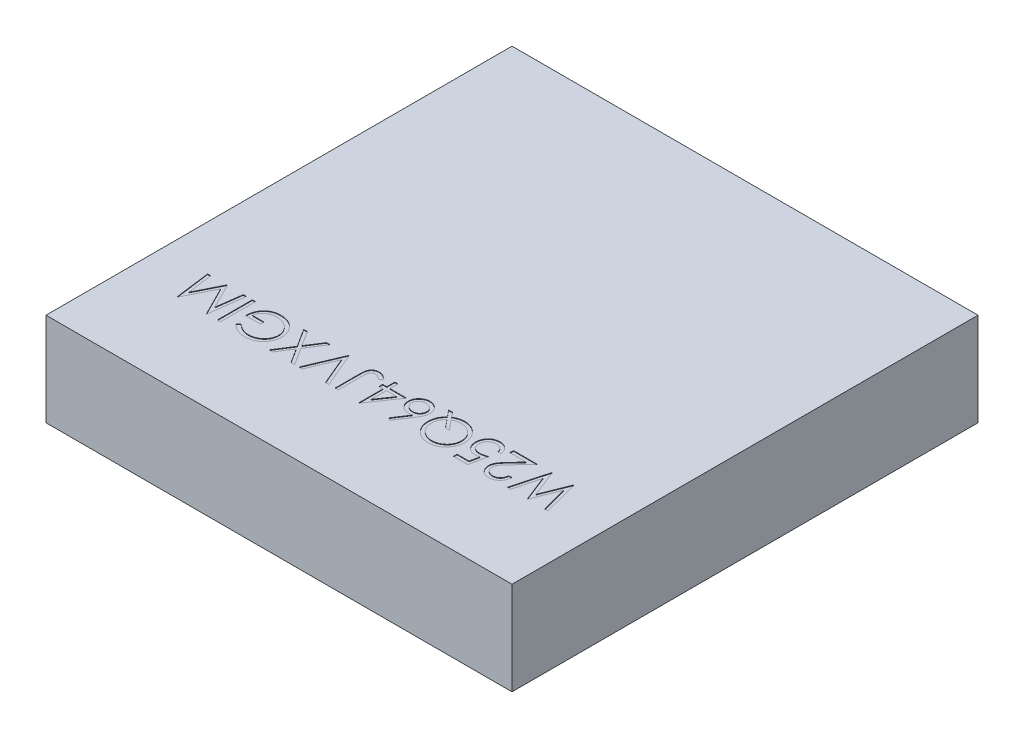
from build123d import *

# Parameters (mm, degrees)
BASES_W          = 4
BASES_H          = 4
BASE_DEPTH       = 0.8
PARTNUMBERS_W    = 0.026923077
PARTNUMBERS_H    = 0.3
PARTNUMBER_DEPTH = 0.005


with BuildPart() as part:
    # BaseS → Base (new body)
    with BuildSketch(Plane(origin=(0, 0, 0), x_dir=(1, 0, 0), z_dir=(0, 1, 0))):
        Rectangle(BASES_W, BASES_H)
    extrude(amount=BASE_DEPTH)

    # PartNumberS → PartNumber (cut)
    with BuildSketch(Plane(origin=(0, 0.8, 0), x_dir=(1, 0, 0), z_dir=(0, 1, 0))):
        Polygon((1.609615385, -1.3), (1.581790865, -1.3), (1.523076923, -1.079987981), (1.435757212, -1.3), (1.431850962, -1.3), (1.346153846, -1.081490385), (1.287139423, -1.3), (1.259615385, -1.3), (1.340504808, -1), (1.344350962, -1), (1.434615385, -1.229447115), (1.525961538, -1), (1.529807692, -1), align=None)
        with BuildLine():
            Line((1.178846154, -1.207692308), (1.205769231, -1.207692308))
            add(Edge.make_bspline(
                [(1.205769231, -1.207692308), (1.20559379, -1.211264116), (1.20524923, -1.218279052), (1.203634954, -1.228506566), (1.201327266, -1.238283593), (1.198056733, -1.247526313), (1.19401791, -1.256345139), (1.189073223, -1.264622965), (1.183328083, -1.272441949), (1.176793031, -1.279654052), (1.169701897, -1.286246815), (1.162097168, -1.29200025), (1.154057007, -1.296805723), (1.14565115, -1.300844834), (1.136782381, -1.303872996), (1.127535475, -1.306120829), (1.117868638, -1.307473016), (1.111282358, -1.307618379), (1.107932692, -1.307692308)],
                knots=[0, 0, 0, 0, 1.100776268, 2.161895295, 3.184016182, 4.190939212, 5.176500551, 6.166955529, 7.155448256, 8.160289653, 9.16017456, 10.133824356, 11.091467644, 12.04088621, 13.000931625, 13.972173743, 14.968683325, 16, 16, 16, 16], degree=3))
            add(Edge.make_bspline(
                [(1.107932692, -1.307692308), (1.104642912, -1.307615922), (1.09817861, -1.307465827), (1.088747998, -1.306157469), (1.079748932, -1.304152528), (1.071283399, -1.301181521), (1.063264519, -1.297453556), (1.055791578, -1.292817344), (1.048683874, -1.287492254), (1.042290239, -1.28121105), (1.036416914, -1.274508988), (1.031354464, -1.267351243), (1.026994641, -1.259949914), (1.023426262, -1.252247187), (1.020721273, -1.244217976), (1.018717135, -1.235939262), (1.017571461, -1.227315502), (1.017396595, -1.221477629), (1.017307692, -1.218509615)],
                knots=[0, 0, 0, 0, 1.111674182, 2.184400057, 3.212814286, 4.223731311, 5.211378316, 6.196328225, 7.191884489, 8.207283132, 9.220262353, 10.201199469, 11.166417575, 12.120932471, 13.06540007, 14.026332106, 14.996573967, 16, 16, 16, 16], degree=3))
            add(Edge.make_bspline(
                [(1.017307692, -1.218509615), (1.017452831, -1.214331231), (1.017740563, -1.206047788), (1.020201761, -1.193875059), (1.024045875, -1.182081438), (1.02867381, -1.172589346), (1.033343795, -1.164941485), (1.03754792, -1.158641505), (1.042497533, -1.151859905), (1.048150348, -1.144569237), (1.054603713, -1.136864979), (1.061689971, -1.128589943), (1.069592128, -1.119897139), (1.075133439, -1.113955969), (1.078004808, -1.110877404)],
                knots=[0, 0, 0, 0, 1.184416499, 2.348048165, 3.509039915, 4.696071444, 5.333504901, 6.05069495, 6.844171097, 7.714965912, 8.667477798, 9.695072654, 10.805644396, 12, 12, 12, 12], degree=3))
            Line((1.078004808, -1.110877404), (1.153064904, -1.030769231))
            Line((1.153064904, -1.030769231), (1.013461538, -1.030769231))
            Line((1.013461538, -1.030769231), (1.013461538, -1))
            Line((1.013461538, -1), (1.217307692, -1))
            Line((1.217307692, -1), (1.100961538, -1.124158654))
            add(Edge.make_bspline(
                [(1.100961538, -1.124158654), (1.098128662, -1.12711549), (1.092687286, -1.132794968), (1.084994275, -1.141089344), (1.0780736, -1.148775115), (1.07192067, -1.15588634), (1.066530422, -1.162382705), (1.061920103, -1.16831512), (1.058069336, -1.173632674), (1.053988325, -1.179879515), (1.050096811, -1.187515589), (1.046676568, -1.196800331), (1.044605999, -1.206379382), (1.044356347, -1.212850661), (1.044230769, -1.216105769)],
                knots=[0, 0, 0, 0, 1.329530082, 2.553755191, 3.672934919, 4.687409497, 5.60679272, 6.413407421, 7.126401618, 7.737995624, 8.834647426, 9.90044882, 10.943907757, 12, 12, 12, 12], degree=3))
            add(Edge.make_bspline(
                [(1.044230769, -1.216105769), (1.044284702, -1.218152972), (1.044390992, -1.222187617), (1.045346826, -1.228099151), (1.046751136, -1.233823625), (1.048915611, -1.23929026), (1.051516148, -1.244606575), (1.054838526, -1.249610936), (1.058635132, -1.254473931), (1.063039008, -1.259028812), (1.067873646, -1.26320179), (1.072981891, -1.266898061), (1.078386142, -1.269987148), (1.084063878, -1.272519442), (1.089999201, -1.274505905), (1.096203609, -1.275882354), (1.102659953, -1.276746568), (1.107068538, -1.276863497), (1.109314904, -1.276923077)],
                knots=[0, 0, 0, 0, 0.991504627, 1.954065223, 2.895985987, 3.842598665, 4.797835564, 5.759220273, 6.74786863, 7.784730864, 8.824135544, 9.839918996, 10.835834653, 11.835434876, 12.84861661, 13.863796685, 14.911511676, 16, 16, 16, 16], degree=3))
            add(Edge.make_bspline(
                [(1.109314904, -1.276923077), (1.111661575, -1.276864225), (1.116270048, -1.276748651), (1.123021768, -1.27587269), (1.12950777, -1.274546092), (1.135628106, -1.272434159), (1.141510864, -1.269962418), (1.147005973, -1.266761947), (1.152267796, -1.263104915), (1.157190543, -1.258841048), (1.161674102, -1.254027783), (1.165752836, -1.24878863), (1.169208787, -1.243030709), (1.1722766, -1.236892182), (1.174622872, -1.230204399), (1.176628766, -1.223130918), (1.178085818, -1.215570817), (1.178588499, -1.210362095), (1.178846154, -1.207692308)],
                knots=[0, 0, 0, 0, 1.031072318, 2.024855787, 2.988461151, 3.935103592, 4.865765533, 5.788564469, 6.724086513, 7.67908574, 8.64457978, 9.611397706, 10.591395687, 11.591555111, 12.622101007, 13.700900657, 14.821571223, 16, 16, 16, 16], degree=3))
        make_face()
        with BuildLine():
            Line((0.798076923, -1.3), (0.798076923, -1.269230769))
            Line((0.798076923, -1.269230769), (0.900120192, -1.269230769))
            Line((0.900120192, -1.269230769), (0.916286058, -1.190324519))
            add(Edge.make_bspline(
                [(0.916286058, -1.190324519), (0.91310984, -1.1912014), (0.90695642, -1.192900217), (0.897874146, -1.194786426), (0.889251958, -1.195923464), (0.883656926, -1.196078719), (0.880949519, -1.196153846)],
                knots=[0, 0, 0, 0, 1.100273476, 2.13160584, 3.095893838, 4, 4, 4, 4], degree=3))
            add(Edge.make_bspline(
                [(0.880949519, -1.196153846), (0.877598881, -1.196083713), (0.871010689, -1.195945814), (0.861386156, -1.194543698), (0.852152981, -1.192511477), (0.843443971, -1.189385532), (0.83511872, -1.185543594), (0.827290097, -1.180767396), (0.819921328, -1.175124996), (0.81302852, -1.168732141), (0.806814411, -1.161614398), (0.801392935, -1.15395507), (0.796758873, -1.145839624), (0.793062265, -1.137193413), (0.790065123, -1.128097917), (0.78808341, -1.118476815), (0.786761219, -1.108410156), (0.786613691, -1.101526862), (0.786538462, -1.098016827)],
                knots=[0, 0, 0, 0, 1.052656913, 2.069786496, 3.052102726, 4.020122636, 4.972424848, 5.930457368, 6.896570172, 7.885826804, 8.881139003, 9.861434336, 10.831623367, 11.813212553, 12.812997731, 13.836986694, 14.897002833, 16, 16, 16, 16], degree=3))
            add(Edge.make_bspline(
                [(0.786538462, -1.098016827), (0.786595512, -1.095572077), (0.786708841, -1.090715617), (0.78728408, -1.08350308), (0.788395237, -1.076444066), (0.789871075, -1.069552559), (0.791833522, -1.062818273), (0.794154213, -1.05622532), (0.796931925, -1.049784606), (0.800101673, -1.04352818), (0.803708016, -1.037579185), (0.807556794, -1.031868302), (0.811750626, -1.026561209), (0.816216097, -1.021569197), (0.821038947, -1.017035846), (0.826100823, -1.012772045), (0.83151492, -1.00895865), (0.837185791, -1.00545142), (0.843109457, -1.002311122), (0.849346093, -0.999691567), (0.855758759, -0.997395501), (0.862404617, -0.995528329), (0.869270792, -0.994079673), (0.876380927, -0.993093158), (0.883699345, -0.992375382), (0.88866005, -0.99233041), (0.891165865, -0.992307692)],
                knots=[0, 0, 0, 0, 1.056281413, 2.098288097, 3.122646807, 4.141030392, 5.140675379, 6.150604744, 7.15845591, 8.168533554, 9.177684096, 10.161739049, 11.141561652, 12.097360316, 13.052218386, 13.998410789, 14.954052752, 15.909851415, 16.877523809, 17.846742625, 18.829312613, 19.818263486, 20.826374662, 21.858017533, 22.918014209, 24, 24, 24, 24], degree=3))
            add(Edge.make_bspline(
                [(0.891165865, -0.992307692), (0.894155001, -0.992367071), (0.900035772, -0.992483893), (0.90865296, -0.993700276), (0.916938622, -0.995454316), (0.924858393, -0.998051627), (0.932375028, -1.001457582), (0.939597564, -1.005478341), (0.946393793, -1.010331237), (0.95281193, -1.015842296), (0.958699488, -1.021954752), (0.964119648, -1.028453213), (0.968812827, -1.035481811), (0.972890737, -1.042923288), (0.976359721, -1.050797044), (0.979087348, -1.059121353), (0.981288177, -1.067855782), (0.982219351, -1.07386892), (0.982692308, -1.076923077)],
                knots=[0, 0, 0, 0, 1.04695683, 2.059763882, 3.044413726, 4.012427942, 4.974081556, 5.932886124, 6.904940154, 7.895678616, 8.893654631, 9.876199664, 10.857615262, 11.850515636, 12.847107701, 13.868396357, 14.917328757, 16, 16, 16, 16], degree=3))
            Line((0.982692308, -1.076923077), (0.955769231, -1.076923077))
            add(Edge.make_bspline(
                [(0.955769231, -1.076923077), (0.955107615, -1.074061664), (0.953835952, -1.068561869), (0.951030105, -1.060843967), (0.947653745, -1.053937781), (0.943452743, -1.047886743), (0.938680855, -1.042487174), (0.933173324, -1.037685484), (0.926976952, -1.033405763), (0.920090356, -1.029809255), (0.912806467, -1.026784158), (0.905227588, -1.024624271), (0.897461334, -1.023317099), (0.892232546, -1.023157283), (0.889603365, -1.023076923)],
                knots=[0, 0, 0, 0, 1.136370375, 2.184166959, 3.172867797, 4.104539607, 5.027679118, 5.956634301, 6.927059835, 7.936867459, 8.959641981, 9.976160943, 10.98235693, 12, 12, 12, 12], degree=3))
            add(Edge.make_bspline(
                [(0.889603365, -1.023076923), (0.887035717, -1.023147864), (0.881979995, -1.023287548), (0.874535895, -1.024345305), (0.867369901, -1.026017165), (0.860469295, -1.028359345), (0.853867983, -1.031457911), (0.8475753, -1.035264321), (0.841501601, -1.039683608), (0.835806736, -1.044734692), (0.830592201, -1.050304151), (0.825984461, -1.056259192), (0.822146459, -1.062612107), (0.818912102, -1.069252652), (0.816456106, -1.076253674), (0.814704022, -1.083582346), (0.813675188, -1.091256773), (0.813533658, -1.096491285), (0.813461538, -1.099158654)],
                knots=[0, 0, 0, 0, 1.027268864, 2.022700798, 3.002744649, 3.968653148, 4.933396556, 5.915045722, 6.907600446, 7.935526002, 8.956456544, 9.95700807, 10.942805781, 11.92166854, 12.907987664, 13.905483474, 14.932689774, 16, 16, 16, 16], degree=3))
            add(Edge.make_bspline(
                [(0.813461538, -1.099158654), (0.813507123, -1.101566891), (0.813596025, -1.106263519), (0.814647396, -1.113128461), (0.816063511, -1.119681428), (0.81829698, -1.12586119), (0.821009843, -1.131732267), (0.824544591, -1.137149588), (0.828452484, -1.142378042), (0.833132454, -1.147071964), (0.838199782, -1.151440438), (0.843815297, -1.155145519), (0.849818518, -1.158297853), (0.856223436, -1.160880247), (0.863037161, -1.162937427), (0.870263578, -1.164359145), (0.877904275, -1.165209886), (0.883130759, -1.165325293), (0.885817308, -1.165384615)],
                knots=[0, 0, 0, 0, 1.045820996, 2.039596555, 3.013371638, 3.9552447, 4.890047302, 5.817684688, 6.761648481, 7.722253242, 8.692244539, 9.66551337, 10.63924952, 11.635311376, 12.662847378, 13.728455105, 14.832366986, 16, 16, 16, 16], degree=3))
            add(Edge.make_bspline(
                [(0.885817308, -1.165384615), (0.888162838, -1.16533654), (0.892964503, -1.165238123), (0.900347055, -1.164463601), (0.90807125, -1.163272073), (0.916167074, -1.161554701), (0.924612311, -1.159404433), (0.933421005, -1.156719017), (0.942593369, -1.153625758), (0.948767027, -1.15122652), (0.951923077, -1.15)],
                knots=[0, 0, 0, 0, 0.824638674, 1.688163388, 2.607705698, 3.571998603, 4.597075385, 5.671199175, 6.809488238, 8, 8, 8, 8], degree=3))
            Line((0.951923077, -1.15), (0.921153846, -1.3))
            Line((0.921153846, -1.3), (0.798076923, -1.3))
        make_face()
        with BuildLine():
            Line((0.478786058, -1.033413462), (0.432692308, -0.976923077))
            Line((0.432692308, -0.976923077), (0.466286058, -0.976923077))
            Line((0.466286058, -0.976923077), (0.499579327, -1.017668269))
            add(Edge.make_bspline(
                [(0.499579327, -1.017668269), (0.502918698, -1.015639694), (0.509535928, -1.011619913), (0.519850263, -1.006428304), (0.530388944, -1.002145891), (0.541056178, -0.998462161), (0.551961456, -0.995732183), (0.563039539, -0.993720919), (0.574315019, -0.992580134), (0.58188862, -0.992398852), (0.585697115, -0.992307692)],
                knots=[0, 0, 0, 0, 1.030168789, 2.04136103, 3.041061446, 4.02840172, 5.015006777, 6.002573162, 6.995564809, 8, 8, 8, 8], degree=3))
            add(Edge.make_bspline(
                [(0.585697115, -0.992307692), (0.591153625, -0.992439365), (0.601890412, -0.992698458), (0.617660577, -0.994952739), (0.632810015, -0.998456665), (0.647299804, -1.003458403), (0.661103922, -1.009950816), (0.67426477, -1.017873954), (0.686786963, -1.027212663), (0.69847894, -1.037876595), (0.70916958, -1.049478728), (0.718550072, -1.061874752), (0.726525993, -1.074859365), (0.732975008, -1.088497215), (0.738093161, -1.102669601), (0.741581044, -1.117494383), (0.74383871, -1.132883314), (0.744098799, -1.1433613), (0.744230769, -1.148677885)],
                knots=[0, 0, 0, 0, 1.05574053, 2.077383083, 3.077194498, 4.061905691, 5.03852134, 6.024727803, 7.030589082, 8.057245348, 9.083652609, 10.080210343, 11.061793968, 12.027891381, 12.99559829, 13.972775731, 14.971375788, 16, 16, 16, 16], degree=3))
            add(Edge.make_bspline(
                [(0.744230769, -1.148677885), (0.744184311, -1.152246375), (0.744091721, -1.159358285), (0.74299987, -1.169909773), (0.741417287, -1.180274816), (0.73910061, -1.190427813), (0.736175249, -1.200392534), (0.732544646, -1.210164017), (0.728269696, -1.219739659), (0.723354163, -1.229062832), (0.717924713, -1.238053903), (0.711946498, -1.246555931), (0.705503786, -1.254566131), (0.6985981, -1.262096521), (0.691167564, -1.269082386), (0.683302231, -1.275571926), (0.674955397, -1.281564252), (0.666169929, -1.28698376), (0.657048827, -1.291869581), (0.647649724, -1.296047211), (0.638087504, -1.299716734), (0.628242101, -1.302560787), (0.618215805, -1.304875066), (0.607951035, -1.306461707), (0.597479726, -1.307557305), (0.590407525, -1.307647032), (0.586838942, -1.307692308)],
                knots=[0, 0, 0, 0, 1.030626684, 2.05401234, 3.061696819, 4.058602899, 5.06035271, 6.060211399, 7.068045458, 8.088070503, 9.103503967, 10.100645233, 11.088606638, 12.071673413, 13.05021482, 14.032855563, 15.015837146, 16.016466104, 17.013321779, 18.002943197, 18.986537994, 19.969996554, 20.961258309, 21.957508933, 22.969373316, 24, 24, 24, 24], degree=3))
            add(Edge.make_bspline(
                [(0.586838942, -1.307692308), (0.581382333, -1.307561519), (0.570665202, -1.307304643), (0.554935238, -1.30504681), (0.539844683, -1.301544957), (0.525400751, -1.296528982), (0.511613801, -1.290048181), (0.49848241, -1.28215756), (0.486026211, -1.272807222), (0.474336878, -1.262201583), (0.463731242, -1.250512251), (0.45438089, -1.238056053), (0.446490322, -1.224924655), (0.440009323, -1.211137731), (0.434994095, -1.196693701), (0.431484898, -1.181584168), (0.429237848, -1.165832556), (0.428978139, -1.155095878), (0.428846154, -1.149639423)],
                knots=[0, 0, 0, 0, 1.050572733, 2.063392076, 3.054553589, 4.030798755, 5.002633919, 5.98401295, 6.976458006, 7.99808884, 9.019719675, 10.012164731, 10.993543762, 11.965378925, 12.941624092, 13.932785605, 14.949427267, 16, 16, 16, 16], degree=3))
            add(Edge.make_bspline(
                [(0.428846154, -1.149639423), (0.428988942, -1.143961549), (0.429269726, -1.132796331), (0.43170018, -1.116454411), (0.43549686, -1.100818649), (0.441035018, -1.085943343), (0.448096067, -1.071733582), (0.456785935, -1.058216831), (0.466933838, -1.045253564), (0.474793711, -1.037401726), (0.478786058, -1.033413462)],
                knots=[0, 0, 0, 0, 1.045555185, 2.056025074, 3.037071613, 4.005098777, 4.973948731, 5.954752269, 6.961136269, 8, 8, 8, 8], degree=3))
        make_face()
        with BuildLine():
            add(Edge.make_bspline(
                [(0.496875, -1.055588942), (0.493601933, -1.058913314), (0.487163664, -1.0654525), (0.478805966, -1.076174377), (0.471643237, -1.087312273), (0.465840141, -1.099007745), (0.46130844, -1.111170392), (0.458128519, -1.123847825), (0.456152054, -1.136977052), (0.455897777, -1.145906518), (0.455769231, -1.150420673)],
                knots=[0, 0, 0, 0, 1.052185505, 2.069695543, 3.06176622, 4.036333774, 5.010523718, 5.985353414, 6.981526144, 8, 8, 8, 8], degree=3))
            add(Edge.make_bspline(
                [(0.455769231, -1.150420673), (0.455802754, -1.153327796), (0.455869024, -1.159074665), (0.456780229, -1.167579024), (0.458069312, -1.175895553), (0.459935511, -1.184009392), (0.462338716, -1.191904104), (0.465306886, -1.19956897), (0.468782189, -1.207028718), (0.472833634, -1.214237009), (0.477300009, -1.221183394), (0.482271632, -1.227782924), (0.487678525, -1.234001568), (0.49346162, -1.239941808), (0.499732416, -1.245481192), (0.506468421, -1.250617347), (0.513586635, -1.255474566), (0.52112228, -1.259858833), (0.528887761, -1.263889483), (0.536837637, -1.267379776), (0.544905157, -1.270335929), (0.553077827, -1.27273299), (0.561345072, -1.274619782), (0.569721387, -1.275907423), (0.578185109, -1.27681769), (0.583871778, -1.276887918), (0.58671875, -1.276923077)],
                knots=[0, 0, 0, 0, 1.032958288, 2.041976502, 3.037103433, 4.023477888, 4.998866292, 5.968231228, 6.943073582, 7.921783703, 8.90545537, 9.876780072, 10.85618943, 11.833110341, 12.821898168, 13.827467856, 14.842673888, 15.88323808, 16.924703457, 17.951432745, 18.967462636, 19.976958182, 20.977218729, 21.979378626, 22.98839684, 24, 24, 24, 24], degree=3))
            add(Edge.make_bspline(
                [(0.58671875, -1.276923077), (0.589585684, -1.276887628), (0.595312187, -1.276816821), (0.603817029, -1.275912987), (0.612211599, -1.274616411), (0.620464772, -1.272748236), (0.62857749, -1.270313855), (0.636603227, -1.267476515), (0.644422341, -1.263911483), (0.652144327, -1.260012481), (0.65958268, -1.255557804), (0.666639635, -1.250710385), (0.673308108, -1.245521127), (0.679521702, -1.239923353), (0.685255302, -1.233879033), (0.690728865, -1.227593834), (0.695631794, -1.220821803), (0.700149598, -1.213749064), (0.704158548, -1.206347162), (0.707726558, -1.198742197), (0.710667652, -1.19089585), (0.713064973, -1.182858631), (0.715027172, -1.1746417), (0.716291149, -1.166195145), (0.717209247, -1.157572295), (0.717274625, -1.151745335), (0.717307692, -1.148798077)],
                knots=[0, 0, 0, 0, 1.013108443, 2.02361456, 3.020252655, 4.015001864, 5.012143058, 6.0135003, 7.021621269, 8.04781341, 9.0704561, 10.084059466, 11.072892162, 12.055670672, 13.03737692, 14.016755907, 14.999789545, 15.989965403, 16.98188718, 17.97360669, 18.957481781, 19.941050972, 20.937387086, 21.941020626, 22.958574714, 24, 24, 24, 24], degree=3))
            add(Edge.make_bspline(
                [(0.717307692, -1.148798077), (0.717194273, -1.144465299), (0.716971142, -1.135941384), (0.715146793, -1.123421163), (0.712021635, -1.111445282), (0.707872959, -1.099914221), (0.702306387, -1.088971993), (0.695630142, -1.078503462), (0.687605941, -1.068651649), (0.678612041, -1.05932254), (0.668712825, -1.050875425), (0.65822443, -1.043430211), (0.647207024, -1.037147139), (0.63571548, -1.031941954), (0.623681241, -1.02796879), (0.61115949, -1.025169998), (0.598150784, -1.023343486), (0.589289085, -1.02316661), (0.584795673, -1.023076923)],
                knots=[0, 0, 0, 0, 1.0224559, 2.011487063, 2.978294593, 3.940186789, 4.898130893, 5.87007047, 6.865534992, 7.892148276, 8.925090732, 9.932666584, 10.923854359, 11.914331309, 12.905710806, 13.90942916, 14.939955271, 16, 16, 16, 16], degree=3))
            add(Edge.make_bspline(
                [(0.584795673, -1.023076923), (0.581708494, -1.023111031), (0.575602273, -1.023178493), (0.566596009, -1.024078527), (0.557841399, -1.025376793), (0.549335459, -1.027223629), (0.54110472, -1.029725893), (0.533097446, -1.032646474), (0.525356987, -1.036133305), (0.520433919, -1.038886029), (0.51796875, -1.040264423)],
                knots=[0, 0, 0, 0, 1.060649269, 2.097889346, 3.10764138, 4.101613775, 5.086194395, 6.062070301, 7.029604192, 8, 8, 8, 8], degree=3))
            Line((0.51796875, -1.040264423), (0.585516827, -1.123076923))
            Line((0.585516827, -1.123076923), (0.551923077, -1.123076923))
            Line((0.551923077, -1.123076923), (0.496875, -1.055588942))
        make_face(mode=Mode.SUBTRACT)
        with BuildLine():
            Line((0.255769231, -1.307692308), (0.235036058, -1.29140625))
            Line((0.235036058, -1.29140625), (0.314302885, -1.170192308))
            add(Edge.make_bspline(
                [(0.314302885, -1.170192308), (0.309025432, -1.171033496), (0.298731165, -1.172674328), (0.288311231, -1.172945009), (0.283233173, -1.173076923)],
                knots=[0, 0, 0, 0, 1.025318673, 2, 2, 2, 2], degree=3))
            add(Edge.make_bspline(
                [(0.283233173, -1.173076923), (0.280184102, -1.172994971), (0.274182096, -1.17283365), (0.265370085, -1.171592177), (0.256902461, -1.169635739), (0.248814324, -1.166783831), (0.241076636, -1.163140774), (0.233645019, -1.158774577), (0.226659067, -1.153459833), (0.220029216, -1.147522726), (0.21400882, -1.140947398), (0.208682809, -1.133968647), (0.204184548, -1.126587027), (0.200600758, -1.118804197), (0.197736676, -1.11068108), (0.195697798, -1.102185995), (0.194478926, -1.093304605), (0.194314362, -1.087263439), (0.194230769, -1.084194712)],
                knots=[0, 0, 0, 0, 1.043709831, 2.054511743, 3.041122595, 4.01515914, 4.98481438, 5.965901842, 6.960491961, 7.985277438, 9.0096037, 10.00832444, 10.987059228, 11.962929573, 12.936966118, 13.931840027, 14.949438142, 16, 16, 16, 16], degree=3))
            add(Edge.make_bspline(
                [(0.194230769, -1.084194712), (0.194387035, -1.079998791), (0.194694347, -1.071747082), (0.196939859, -1.059680952), (0.200786539, -1.04828486), (0.206015652, -1.037529051), (0.21267083, -1.027638773), (0.220653213, -1.018730338), (0.229923391, -1.01096539), (0.24029679, -1.004307084), (0.251522513, -0.999016307), (0.26329345, -0.995104922), (0.275508505, -0.992767726), (0.283804225, -0.992461742), (0.287980769, -0.992307692)],
                knots=[0, 0, 0, 0, 1.0319111, 2.029359566, 3.00642934, 3.98275322, 4.962714161, 5.929339302, 6.915525103, 7.928435063, 8.953439721, 9.960121214, 10.9730072, 12, 12, 12, 12], degree=3))
            add(Edge.make_bspline(
                [(0.287980769, -0.992307692), (0.2920178, -0.992438309), (0.300014451, -0.992697037), (0.311774766, -0.995013853), (0.323095059, -0.99874228), (0.33382976, -1.003986656), (0.3437911, -1.01049873), (0.352771453, -1.018285019), (0.360543584, -1.027350575), (0.367035262, -1.03752623), (0.372347633, -1.048374404), (0.376059465, -1.059809031), (0.378472793, -1.07159313), (0.378721144, -1.079615626), (0.378846154, -1.083653846)],
                knots=[0, 0, 0, 0, 1.01206923, 2.004731945, 2.994948482, 3.995280086, 4.993424783, 5.973125358, 6.967517142, 7.97830003, 8.994392566, 9.989381197, 10.98793077, 12, 12, 12, 12], degree=3))
            add(Edge.make_bspline(
                [(0.378846154, -1.083653846), (0.37873743, -1.086742257), (0.378515535, -1.093045396), (0.37719129, -1.10261929), (0.374762464, -1.112377053), (0.372133943, -1.120648966), (0.369525656, -1.127499609), (0.367107193, -1.132909381), (0.364403057, -1.138622273), (0.361233432, -1.144530193), (0.357873375, -1.150801942), (0.353948446, -1.157205259), (0.349852723, -1.163974012), (0.3468523, -1.168480543), (0.3453125, -1.170793269)],
                knots=[0, 0, 0, 0, 1.17367173, 2.395347028, 3.66355231, 4.98980831, 5.690886799, 6.447442954, 7.240630024, 8.091733897, 8.994365608, 9.943299771, 10.944512865, 12, 12, 12, 12], degree=3))
            Line((0.3453125, -1.170793269), (0.255769231, -1.307692308))
        make_face()
        with BuildLine():
            add(Edge.make_bspline(
                [(0.288882212, -1.142307692), (0.291167701, -1.142240769), (0.295651813, -1.142109465), (0.302218515, -1.141351509), (0.308437191, -1.139964238), (0.314297637, -1.138011517), (0.319886341, -1.135625796), (0.325114531, -1.132600408), (0.330017394, -1.129042616), (0.334481706, -1.124947647), (0.338582122, -1.120532678), (0.342108879, -1.115774741), (0.345154447, -1.110820121), (0.347629823, -1.105622007), (0.3495576, -1.100183798), (0.350952006, -1.094530131), (0.351728046, -1.088623195), (0.351857151, -1.084617552), (0.351923077, -1.082572115)],
                knots=[0, 0, 0, 0, 1.129540697, 2.216149546, 3.260829642, 4.271906843, 5.264942922, 6.258225651, 7.250175744, 8.252297429, 9.247108021, 10.223125336, 11.173816288, 12.116901384, 13.062424938, 14.020354563, 14.989116641, 16, 16, 16, 16], degree=3))
            add(Edge.make_bspline(
                [(0.351923077, -1.082572115), (0.351867349, -1.080545405), (0.351757531, -1.076551525), (0.350826845, -1.070687588), (0.349328729, -1.065062632), (0.347199046, -1.059664789), (0.344478321, -1.054502267), (0.341224189, -1.049512657), (0.337278275, -1.044828777), (0.332795633, -1.04042172), (0.327924726, -1.036388902), (0.322784108, -1.032783324), (0.317355335, -1.029790623), (0.311696222, -1.02728915), (0.305735672, -1.025451394), (0.299574625, -1.024043464), (0.29312818, -1.023273952), (0.288763864, -1.023143461), (0.286538462, -1.023076923)],
                knots=[0, 0, 0, 0, 0.98953633, 1.950002717, 2.892353065, 3.828177645, 4.777967117, 5.738732544, 6.732276577, 7.76327951, 8.805689376, 9.818183401, 10.825652611, 11.829169732, 12.834974292, 13.867693979, 14.912718532, 16, 16, 16, 16], degree=3))
            add(Edge.make_bspline(
                [(0.286538462, -1.023076923), (0.284313055, -1.023143456), (0.279948732, -1.023273936), (0.273502339, -1.024043522), (0.2673411, -1.025451181), (0.261381247, -1.027289924), (0.255719552, -1.029787734), (0.250286029, -1.032802189), (0.245096328, -1.036367044), (0.240228589, -1.040428694), (0.23572724, -1.044803777), (0.231871997, -1.049555472), (0.228512921, -1.054462999), (0.225895956, -1.059685323), (0.223742429, -1.065059422), (0.222251652, -1.070688464), (0.221318981, -1.076551296), (0.221209435, -1.080545328), (0.221153846, -1.082572115)],
                knots=[0, 0, 0, 0, 1.087095469, 2.131941252, 3.164484274, 4.170116773, 5.173462224, 6.180759088, 7.201132453, 8.243363996, 9.274190558, 10.261329848, 11.227346438, 12.172477233, 13.108141724, 14.050330866, 15.010632948, 16, 16, 16, 16], degree=3))
            add(Edge.make_bspline(
                [(0.221153846, -1.082572115), (0.221200464, -1.084620457), (0.221291961, -1.088640687), (0.222346876, -1.094524809), (0.223771714, -1.100229772), (0.226074384, -1.105627056), (0.228817047, -1.110865936), (0.23231104, -1.115796618), (0.23631691, -1.120559034), (0.240956405, -1.124976911), (0.246002595, -1.129020714), (0.251373133, -1.132579598), (0.256969073, -1.135617572), (0.262869512, -1.13801475), (0.268994988, -1.13994595), (0.275387819, -1.141342217), (0.282052547, -1.142110645), (0.28657666, -1.142241173), (0.288882212, -1.142307692)],
                knots=[0, 0, 0, 0, 0.978317929, 1.920119929, 2.851929572, 3.784133089, 4.71845084, 5.67514162, 6.667477147, 7.690549442, 8.733345855, 9.756283585, 10.767808623, 11.772962645, 12.797066014, 13.836159554, 14.89727653, 16, 16, 16, 16], degree=3))
        make_face(mode=Mode.SUBTRACT)
        Polygon((-0.000300481, -1.307692308), (-0.005769231, -1.307692308), (-0.005769231, -1.1), (-0.040384615, -1.1), (-0.040384615, -1.069230769), (-0.005769231, -1.069230769), (-0.005769231, -1), (0.021153846, -1), (0.021153846, -1.069230769), (0.163461538, -1.069230769), align=None)
        Polygon((0.021153846, -1.1), (0.021153846, -1.230288462), (0.110576923, -1.1), align=None, mode=Mode.SUBTRACT)
        with BuildLine():
            Line((-0.190384615, -1.3), (-0.217307692, -1.3))
            Line((-0.217307692, -1.3), (-0.217307692, -1.097415865))
            add(Edge.make_bspline(
                [(-0.217307692, -1.097415865), (-0.217280907, -1.093669689), (-0.217229476, -1.086476573), (-0.216943776, -1.076116202), (-0.216422313, -1.066635108), (-0.215638393, -1.058058741), (-0.214704455, -1.05037385), (-0.213518724, -1.043569157), (-0.212108488, -1.037641815), (-0.209973171, -1.030989495), (-0.206492345, -1.023667883), (-0.201149372, -1.015831539), (-0.194652476, -1.008901668), (-0.187018189, -1.003005381), (-0.178410491, -0.998138081), (-0.168793758, -0.994736787), (-0.158344033, -0.992640371), (-0.151092027, -0.992420811), (-0.147355769, -0.992307692)],
                knots=[0, 0, 0, 0, 1.23761369, 2.376369303, 3.423688776, 4.373947637, 5.221061685, 5.980504468, 6.65465141, 7.232267317, 8.286152468, 9.319580031, 10.354278202, 11.410653829, 12.495036873, 13.606623453, 14.766924254, 16, 16, 16, 16], degree=3))
            add(Edge.make_bspline(
                [(-0.147355769, -0.992307692), (-0.144424992, -0.992398973), (-0.138568101, -0.992581389), (-0.129826052, -0.994106164), (-0.121163232, -0.996501439), (-0.112450628, -0.999944484), (-0.103578948, -1.004606642), (-0.09432038, -1.010629989), (-0.084690319, -1.018174261), (-0.078329568, -1.023917007), (-0.075, -1.026923077)],
                knots=[0, 0, 0, 0, 0.854547984, 1.707735923, 2.581180402, 3.47327429, 4.435225703, 5.500268456, 6.691502816, 8, 8, 8, 8], degree=3))
            Line((-0.075, -1.026923077), (-0.090865385, -1.05))
            add(Edge.make_bspline(
                [(-0.090865385, -1.05), (-0.094533275, -1.047488638), (-0.101453357, -1.042750538), (-0.111516337, -1.036460597), (-0.120600788, -1.031350645), (-0.126485405, -1.028651882), (-0.129206731, -1.027403846)],
                knots=[0, 0, 0, 0, 1.196638425, 2.257656398, 3.194257951, 4, 4, 4, 4], degree=3))
            add(Edge.make_bspline(
                [(-0.129206731, -1.027403846), (-0.130855572, -1.026721708), (-0.134078089, -1.025388528), (-0.139076657, -1.024113979), (-0.14397606, -1.023191068), (-0.14725144, -1.023114489), (-0.148858173, -1.023076923)],
                knots=[0, 0, 0, 0, 1.055403208, 2.062694816, 3.049657822, 4, 4, 4, 4], degree=3))
            add(Edge.make_bspline(
                [(-0.148858173, -1.023076923), (-0.150931085, -1.023163391), (-0.155008984, -1.023333492), (-0.160968985, -1.024876403), (-0.16665064, -1.027260676), (-0.171917731, -1.030676835), (-0.176713578, -1.03474792), (-0.180743396, -1.039605439), (-0.184017156, -1.045069856), (-0.186104499, -1.050198292), (-0.187360445, -1.054915435), (-0.188192874, -1.059231149), (-0.188795144, -1.064296799), (-0.189444114, -1.07008025), (-0.189793682, -1.076621266), (-0.190201408, -1.083889718), (-0.190346545, -1.091906541), (-0.190371538, -1.097496029), (-0.190384615, -1.100420673)],
                knots=[0, 0, 0, 0, 0.997338315, 1.961996122, 2.948199042, 3.955162468, 4.975046525, 5.968827587, 6.982064989, 8.034375777, 8.624523585, 9.332616724, 10.150461195, 11.082242492, 12.136676661, 13.306224245, 14.590509051, 16, 16, 16, 16], degree=3))
            Line((-0.190384615, -1.100420673), (-0.190384615, -1.3))
        make_face()
        Polygon((-0.271153846, -1.3), (-0.3, -1.3), (-0.4, -1.063581731), (-0.5, -1.3), (-0.528846154, -1.3), (-0.401923077, -1), (-0.398076923, -1), align=None)
        Polygon((-0.565384615, -1.3), (-0.596454327, -1.3), (-0.675, -1.177283654), (-0.753545673, -1.3), (-0.784615385, -1.3), (-0.690564904, -1.153004808), (-0.788461538, -1), (-0.757391827, -1), (-0.675, -1.128725962), (-0.592608173, -1), (-0.561538462, -1), (-0.659495192, -1.153004808), align=None)
        with BuildLine():
            Line((-1.121153846, -1.248798077), (-1.098076923, -1.226923077))
            add(Edge.make_bspline(
                [(-1.098076923, -1.226923077), (-1.093876566, -1.230846042), (-1.085598311, -1.238577601), (-1.072166465, -1.248721059), (-1.058133034, -1.257342708), (-1.04361211, -1.264426049), (-1.028883713, -1.26993218), (-1.014241893, -1.273913403), (-0.999789305, -1.276473815), (-0.990194391, -1.276774573), (-0.985456731, -1.276923077)],
                knots=[0, 0, 0, 0, 1.091957225, 2.152079168, 3.193085318, 4.218301889, 5.218403563, 6.17723952, 7.099979378, 8, 8, 8, 8], degree=3))
            add(Edge.make_bspline(
                [(-0.985456731, -1.276923077), (-0.982549773, -1.276887573), (-0.976743396, -1.276816656), (-0.968118415, -1.275913645), (-0.959585044, -1.274610875), (-0.951172709, -1.272745295), (-0.942847963, -1.270322222), (-0.934629327, -1.267396723), (-0.926532663, -1.263875046), (-0.918600564, -1.259860012), (-0.910871457, -1.255476942), (-0.903602191, -1.250588521), (-0.896762451, -1.24534518), (-0.890400607, -1.239678155), (-0.884429513, -1.233681765), (-0.878958475, -1.22727081), (-0.873867848, -1.220540177), (-0.86934804, -1.213393388), (-0.8652628, -1.206033507), (-0.861725331, -1.198519201), (-0.858679364, -1.190903469), (-0.856245451, -1.183182015), (-0.854288679, -1.175359772), (-0.852903649, -1.16744896), (-0.852125716, -1.159410604), (-0.851990867, -1.154028018), (-0.851923077, -1.151322115)],
                knots=[0, 0, 0, 0, 1.028307134, 2.053947307, 3.065600992, 4.082111276, 5.100671203, 6.132125737, 7.167228006, 8.222953114, 9.277225349, 10.309459149, 11.320441984, 12.324791754, 13.322338422, 14.312705492, 15.305176196, 16.306142747, 17.302479595, 18.282363326, 19.243345101, 20.20291386, 21.145121196, 22.094978082, 23.042318507, 24, 24, 24, 24], degree=3))
            add(Edge.make_bspline(
                [(-0.851923077, -1.151322115), (-0.851988472, -1.148556214), (-0.852119084, -1.143031963), (-0.852937862, -1.134784241), (-0.854508659, -1.126675826), (-0.856427369, -1.118630224), (-0.859143249, -1.110750127), (-0.862300376, -1.102920133), (-0.866107163, -1.095213012), (-0.870490764, -1.087682488), (-0.875335112, -1.080354119), (-0.880662175, -1.073392992), (-0.886482012, -1.06688046), (-0.892687623, -1.060721306), (-0.899335626, -1.054954427), (-0.906490499, -1.049649325), (-0.914052093, -1.044723969), (-0.922023761, -1.040232469), (-0.930321245, -1.036220409), (-0.938828939, -1.03265262), (-0.947574187, -1.029714398), (-0.956510987, -1.027319701), (-0.965628697, -1.025356819), (-0.974973594, -1.024094035), (-0.984476969, -1.023177678), (-0.990883138, -1.023110678), (-0.994110577, -1.023076923)],
                knots=[0, 0, 0, 0, 0.935896426, 1.86923723, 2.799743935, 3.728471844, 4.66505513, 5.616527375, 6.583419551, 7.570341864, 8.562833498, 9.553750335, 10.533080376, 11.5155245, 12.510142773, 13.507781369, 14.526649666, 15.561487327, 16.601173999, 17.643331812, 18.680652164, 19.71969803, 20.772446191, 21.833473655, 22.9085001, 24, 24, 24, 24], degree=3))
            add(Edge.make_bspline(
                [(-0.994110577, -1.023076923), (-0.998000165, -1.023158196), (-1.005638004, -1.023317788), (-1.016865189, -1.024561149), (-1.027649128, -1.02650056), (-1.037954711, -1.029349623), (-1.047819356, -1.032955827), (-1.057206615, -1.037415444), (-1.066142648, -1.042681405), (-1.074587888, -1.048647626), (-1.08234483, -1.055293375), (-1.089395452, -1.062406597), (-1.095533147, -1.070044048), (-1.100797943, -1.078204067), (-1.105329417, -1.0867665), (-1.108944114, -1.095878105), (-1.111739907, -1.105437112), (-1.112883632, -1.112045502), (-1.113461538, -1.115384615)],
                knots=[0, 0, 0, 0, 1.130234505, 2.219399076, 3.279128566, 4.311639422, 5.322903917, 6.328167287, 7.327698761, 8.334124803, 9.329374007, 10.292761544, 11.24113083, 12.171311216, 13.111441694, 14.052040787, 15.015727358, 16, 16, 16, 16], degree=3))
            Line((-1.113461538, -1.115384615), (-1.013461538, -1.115384615))
            Line((-1.013461538, -1.115384615), (-1.013461538, -1.146153846))
            Line((-1.013461538, -1.146153846), (-1.140384615, -1.146153846))
            add(Edge.make_bspline(
                [(-1.140384615, -1.146153846), (-1.1402384, -1.140418919), (-1.13995223, -1.129194629), (-1.137944894, -1.112825749), (-1.134703479, -1.097365318), (-1.130275452, -1.082797055), (-1.124543285, -1.069141604), (-1.117568497, -1.056385101), (-1.109239458, -1.044609957), (-1.099852849, -1.033720042), (-1.089318566, -1.02400611), (-1.077921256, -1.015468458), (-1.065642087, -1.008276805), (-1.052492675, -1.002425891), (-1.038516067, -0.997859549), (-1.02367992, -0.994621985), (-1.008004354, -0.992682274), (-0.99726121, -0.992434442), (-0.991766827, -0.992307692)],
                knots=[0, 0, 0, 0, 1.140356446, 2.231883559, 3.274166699, 4.278491846, 5.25512956, 6.21435461, 7.1637429, 8.11826594, 9.068280886, 10.0076534, 10.945064095, 11.891975133, 12.864533718, 13.863980011, 14.907571808, 16, 16, 16, 16], degree=3))
            add(Edge.make_bspline(
                [(-0.991766827, -0.992307692), (-0.988380244, -0.992356474), (-0.981700811, -0.992452688), (-0.971835874, -0.99313646), (-0.962242935, -0.994189081), (-0.952923391, -0.995778663), (-0.943842962, -0.997725633), (-0.935046998, -1.000218781), (-0.926501991, -1.003104669), (-0.918194735, -1.006387156), (-0.910200631, -1.01019044), (-0.902484073, -1.014416981), (-0.895002405, -1.019044983), (-0.887806591, -1.024154484), (-0.880859137, -1.029707267), (-0.874204842, -1.03571446), (-0.867806453, -1.042157699), (-0.863798413, -1.046733042), (-0.861778846, -1.049038462)],
                knots=[0, 0, 0, 0, 1.107784379, 2.184907829, 3.233506516, 4.263428166, 5.276301166, 6.270063455, 7.25232949, 8.225834625, 9.190232166, 10.146266622, 11.1027726, 12.066435141, 13.031522626, 14.010570082, 14.99756817, 16, 16, 16, 16], degree=3))
            add(Edge.make_bspline(
                [(-0.861778846, -1.049038462), (-0.858848623, -1.052695946), (-0.853036817, -1.059950205), (-0.845555832, -1.071573057), (-0.839178569, -1.083607502), (-0.834004184, -1.096087042), (-0.829963777, -1.109000003), (-0.827066098, -1.122329885), (-0.82536833, -1.136093853), (-0.825123741, -1.145408019), (-0.825, -1.150120192)],
                knots=[0, 0, 0, 0, 1.023165419, 2.029347347, 3.013907458, 3.994755782, 4.975994455, 5.96558838, 6.970761222, 8, 8, 8, 8], degree=3))
            add(Edge.make_bspline(
                [(-0.825, -1.150120192), (-0.825045744, -1.153648691), (-0.825136651, -1.160660844), (-0.826234162, -1.171072016), (-0.827818229, -1.181295748), (-0.830112688, -1.191341507), (-0.833131622, -1.201164693), (-0.836757245, -1.210840787), (-0.84100388, -1.220331115), (-0.845959549, -1.229551561), (-0.851353736, -1.238498973), (-0.857419415, -1.246891728), (-0.863819626, -1.254892107), (-0.870860995, -1.262273604), (-0.878279667, -1.269272029), (-0.886260171, -1.275702924), (-0.894671573, -1.281674791), (-0.903581795, -1.28707077), (-0.912849501, -1.291919469), (-0.922454746, -1.296169869), (-0.932393985, -1.299682753), (-0.942592919, -1.302663355), (-0.953128703, -1.304867512), (-0.963924892, -1.306465975), (-0.975037759, -1.307559741), (-0.982549419, -1.307647706), (-0.986358173, -1.307692308)],
                knots=[0, 0, 0, 0, 1.009025537, 2.005226976, 2.991671811, 3.967589759, 4.950148279, 5.929425679, 6.922109907, 7.921964004, 8.922507644, 9.908469609, 10.882248289, 11.851158214, 12.824245259, 13.798023939, 14.780666017, 15.773333703, 16.775582742, 17.771174102, 18.775387309, 19.789283316, 20.80873549, 21.851817535, 22.910773411, 24, 24, 24, 24], degree=3))
            add(Edge.make_bspline(
                [(-0.986358173, -1.307692308), (-0.989464331, -1.307642761), (-0.995623477, -1.307544516), (-1.004788207, -1.306860015), (-1.013793237, -1.305787112), (-1.022683739, -1.304286836), (-1.031425863, -1.302302215), (-1.040046093, -1.299883535), (-1.048528126, -1.297083172), (-1.056861872, -1.293740789), (-1.065103991, -1.289947753), (-1.07330014, -1.285677994), (-1.081422364, -1.280858718), (-1.089484733, -1.275475555), (-1.097538092, -1.269620977), (-1.105455062, -1.263127535), (-1.113426743, -1.256251299), (-1.118552612, -1.251307112), (-1.121153846, -1.248798077)],
                knots=[0, 0, 0, 0, 0.985875312, 1.954874891, 2.915472732, 3.863573565, 4.815313299, 5.759461513, 6.704487138, 7.649063459, 8.607849844, 9.583336382, 10.581114205, 11.603942397, 12.659508253, 13.739925933, 14.853076422, 16, 16, 16, 16], degree=3))
        make_face()
        with Locations((-1.215384616, -1.15)):
            Rectangle(PARTNUMBERS_W, PARTNUMBERS_H)
        Polygon((-1.278846154, -1), (-1.318449519, -1.3), (-1.322295673, -1.3), (-1.446153846, -1.053846154), (-1.569711538, -1.3), (-1.573617788, -1.3), (-1.613461538, -1), (-1.586418269, -1), (-1.557692308, -1.215865385), (-1.449399038, -1), (-1.443329327, -1), (-1.334615385, -1.216346154), (-1.305949519, -1), align=None)
    extrude(amount=-PARTNUMBER_DEPTH, mode=Mode.SUBTRACT)


solid = part.part
